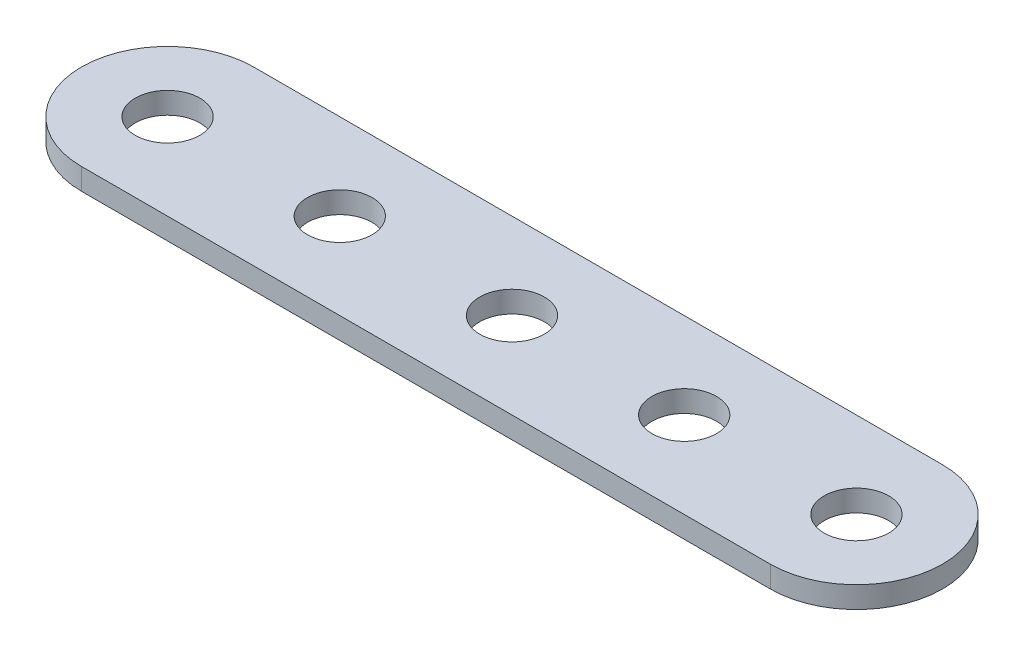
from build123d import *

# Parameters (mm, degrees)
SKETCH1_R           = 2.38125
BOSS_EXTRUDE1_DEPTH = 1.5875


with BuildPart() as part:
    # Sketch1 → Boss-Extrude1 (new body)
    with BuildSketch(Plane(origin=(0, 0, 0), x_dir=(1, 0, 0), z_dir=(0, 1, 0))):
        with BuildLine():
            Line((-25.4, -6.35), (25.4, -6.35))
            ThreePointArc((25.4, -6.35), (31.75, 0), (25.4, 6.35))
            Line((25.4, 6.35), (-25.4, 6.35))
            ThreePointArc((-25.4, 6.35), (-31.75, 0), (-25.4, -6.35))
        make_face()
        with Locations((-25.4, 0)):
            Circle(SKETCH1_R, mode=Mode.SUBTRACT)
        with Locations((-12.7, 0)):
            Circle(SKETCH1_R, mode=Mode.SUBTRACT)
        Circle(SKETCH1_R, mode=Mode.SUBTRACT)
        with Locations((12.7, 0)):
            Circle(SKETCH1_R, mode=Mode.SUBTRACT)
        with Locations((25.4, 0)):
            Circle(SKETCH1_R, mode=Mode.SUBTRACT)
    extrude(amount=BOSS_EXTRUDE1_DEPTH)


solid = part.part
